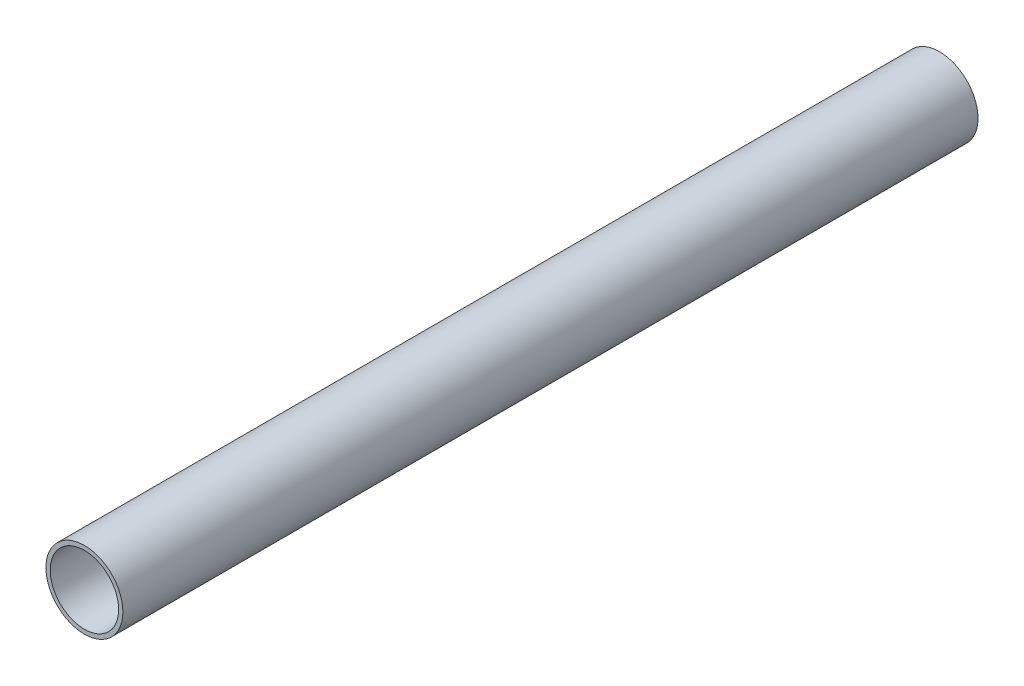
from build123d import *

# Parameters (mm, degrees)
SKETCH1_R           = 2.25
SKETCH1_R_2         = 2
BOSS_EXTRUDE1_DEPTH = 50


with BuildPart() as part:
    # Sketch1 → Boss-Extrude1 (new body)
    with BuildSketch(Plane.XY):
        Circle(SKETCH1_R)
        Circle(SKETCH1_R_2, mode=Mode.SUBTRACT)
    extrude(amount=BOSS_EXTRUDE1_DEPTH)


solid = part.part
